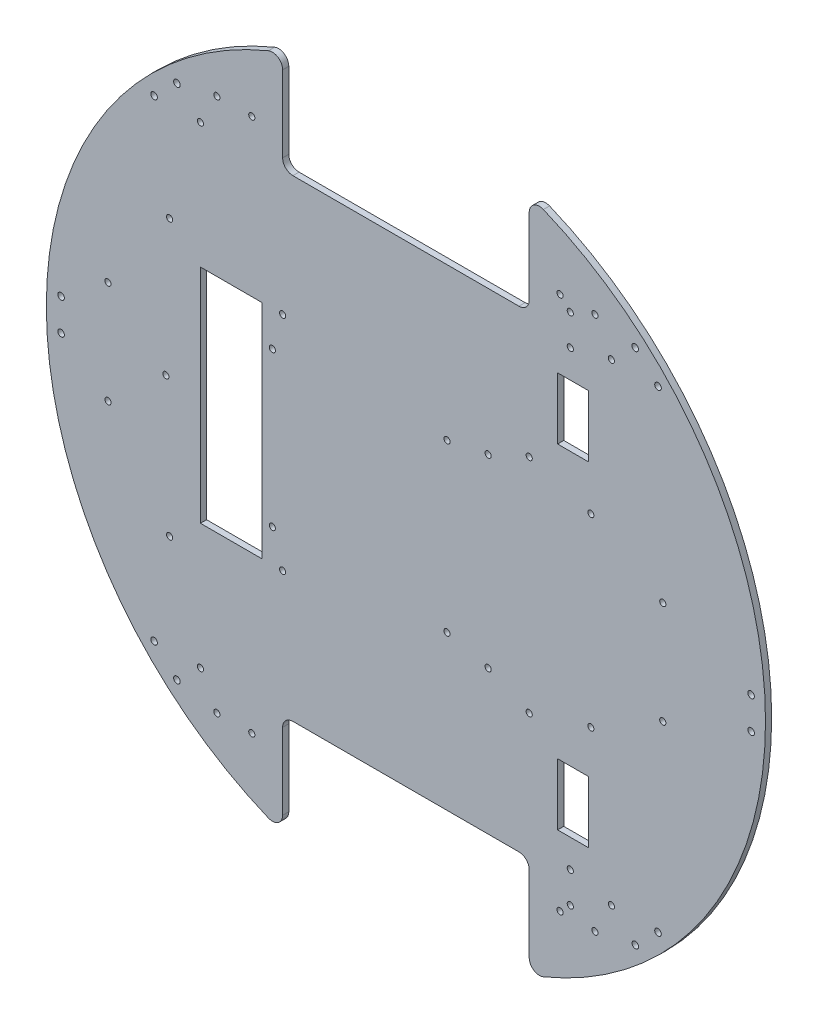
from build123d import *

# Parameters (mm, degrees)
SKETCH_1_R             = 175
EXTRUDE_1_DEPTH        = 3
CUT_EXTRUDE_1_DEPTH    = 3
FILLET_1_R             = 5
FILLET_2_R             = 5
FILLET_3_R             = 5
SKETCH_5_R             = 1.5
CUT_EXTRUDE_4_DEPTH    = 3
SKETCH_6_R             = 1.5
CUT_EXTRUDE_5_DEPTH    = 3
SKETCH_7_W             = 30
SKETCH_7_H             = 108
CUT_EXTRUDE_6_DEPTH    = 3
SKETCH_8_R             = 1.5
CUT_EXTRUDE_7_DEPTH    = 3
SKETCH_9_R             = 1.5
CUT_EXTRUDE_8_DEPTH    = 10
SKETCH_10_R            = 1.6
CUT_EXTRUDE_5158_DEPTH = 10
SKETCH_11_W            = 15
SKETCH_11_H            = 30
CUT_EXTRUDE_10_DEPTH   = 10
SKETCH_19_R            = 1.6
CUT_EXTRUDE_8157_DEPTH = 10
SKETCH_21_R            = 1.5
WEB_DEPTH              = 10
SKETCH_22_R            = 1.5
WEB_2_DEPTH            = 10
SKETCH_28_R            = 1.5
CUT_EXTRUDE_9035_DEPTH = 10
SKETCH_29_R            = 1.5
CUT_EXTRUDE_9316_DEPTH = 10
SKETCH_31_R            = 1.5
CUT_EXTRUDE_9726_DEPTH = 10


with BuildPart() as part:
    # ｽｹｯﾁ1 → ﾎﾞｽ - 押し出し1 (new body)
    with BuildSketch(Plane.XY):
        Circle(SKETCH_1_R)
    extrude(amount=EXTRUDE_1_DEPTH)

    # ｽｹｯﾁ2 → ｶｯﾄ - 押し出し1 (cut)
    with BuildSketch(Plane.XY.offset(3)):
        with BuildLine():
            Line((-60, 115), (0, 115))
            Line((0, 115), (0, 175))
            ThreePointArc((0, 175), (-30.465194158, 172.327803749), (-60, 164.392822228))
            Line((-60, 164.392822228), (-60, 115))
        make_face()
        with BuildLine():
            Line((0, 175), (0, 115))
            Line((0, 115), (60, 115))
            Line((60, 115), (60, 164.392822228))
            ThreePointArc((60, 164.392822228), (30.465194158, 172.327803749), (0, 175))
        make_face()
        with BuildLine():
            Line((0, -175), (0, -115))
            Line((0, -115), (-60, -115))
            Line((-60, -115), (-60, -164.392822228))
            ThreePointArc((-60, -164.392822228), (-30.465194158, -172.327803749), (0, -175))
        make_face()
        with BuildLine():
            Line((60, -115), (0, -115))
            Line((0, -115), (0, -175))
            ThreePointArc((0, -175), (30.465194158, -172.327803749), (60, -164.392822228))
            Line((60, -164.392822228), (60, -115))
        make_face()
    extrude(amount=-CUT_EXTRUDE_1_DEPTH, mode=Mode.SUBTRACT)

    # ﾌｨﾚｯﾄ1
    fillet_1_edges = [part.edges().sort_by_distance(p)[0] for p in [
        (-60, 164.392822228, 1.5),
    ]]
    fillet(fillet_1_edges, radius=FILLET_1_R)

    # ﾌｨﾚｯﾄ2
    fillet_2_edges = [part.edges().sort_by_distance(p)[0] for p in [
        (-60, 115, 1.5),
        (60, 164.392822228, 1.5),
        (60, 115, 1.5),
    ]]
    fillet(fillet_2_edges, radius=FILLET_2_R)

    # ﾌｨﾚｯﾄ3
    fillet_3_edges = [part.edges().sort_by_distance(p)[0] for p in [
        (-60, -115, 1.5),
        (60, -115, 1.5),
        (60, -164.392822228, 1.5),
        (-60, -164.392822228, 1.5),
    ]]
    fillet(fillet_3_edges, radius=FILLET_3_R)

    # ｽｹｯﾁ5 → ｶｯﾄ - 押し出し4 (cut)
    with BuildSketch(Plane.XY.offset(3)):
        with Locations((-100, -115)):
            Circle(SKETCH_5_R)
        with Locations((100, -115)):
            Circle(SKETCH_5_R)
        with Locations((100, 115)):
            Circle(SKETCH_5_R)
        with Locations((-100, 115)):
            Circle(SKETCH_5_R)
    extrude(amount=-CUT_EXTRUDE_4_DEPTH, mode=Mode.SUBTRACT)

    # ｽｹｯﾁ6 → ｶｯﾄ - 押し出し5 (cut)
    with BuildSketch(Plane.XY.offset(3)):
        with Locations((-60, 54)):
            Circle(SKETCH_6_R)
        with Locations((60, 54)):
            Circle(SKETCH_6_R)
        with Locations((-60, -54)):
            Circle(SKETCH_6_R)
        with Locations((60, -54)):
            Circle(SKETCH_6_R)
    extrude(amount=-CUT_EXTRUDE_5_DEPTH, mode=Mode.SUBTRACT)

    # ｽｹｯﾁ7 → ｶｯﾄ - 押し出し6 (cut)
    with BuildSketch(Plane.XY.offset(3)):
        with Locations((-85, 0)):
            Rectangle(SKETCH_7_W, SKETCH_7_H)
    extrude(amount=-CUT_EXTRUDE_6_DEPTH, mode=Mode.SUBTRACT)

    # ｽｹｯﾁ8 → ｶｯﾄ - 押し出し7 (cut)
    with BuildSketch(Plane.XY.offset(3)):
        with Locations((-115, -67)):
            Circle(SKETCH_8_R)
        with Locations((-116.822468618, 0)):
            Circle(SKETCH_8_R)
        with Locations((-115, 67)):
            Circle(SKETCH_8_R)
    extrude(amount=-CUT_EXTRUDE_7_DEPTH, mode=Mode.SUBTRACT)

    # ｽｹｯﾁ9 → ｶｯﾄ - 押し出し8 (cut)
    with BuildSketch(Plane.XY.offset(3)):
        with Locations((-65, 37)):
            Circle(SKETCH_9_R)
        with Locations((20, 41)):
            Circle(SKETCH_9_R)
        with Locations((-65, -38)):
            Circle(SKETCH_9_R)
        with Locations((20, -40)):
            Circle(SKETCH_9_R)
    extrude(amount=-CUT_EXTRUDE_8_DEPTH, mode=Mode.SUBTRACT)

    # ｽｹｯﾁ10 → Cut-Extrude 5158 (cut)
    with BuildSketch(Plane.XY.offset(3)):
        with Locations((111.643659725, -125.921059639)):
            Circle(SKETCH_10_R)
        with Locations((122.679794489, -115.037952538)):
            Circle(SKETCH_10_R)
        with Locations((168, 7.75)):
            Circle(SKETCH_10_R)
        with Locations((168, -7.75)):
            Circle(SKETCH_10_R)
        with Locations((111.56768007, 125.844011632)):
            Circle(SKETCH_10_R)
        with Locations((122.679794489, 115.037952538)):
            Circle(SKETCH_10_R)
    extrude(amount=-CUT_EXTRUDE_5158_DEPTH, mode=Mode.SUBTRACT)

    # ｽｹｯﾁ11 → ｶｯﾄ - 押し出し10 (cut)
    with BuildSketch(Plane.XY.offset(3)):
        with Locations((81.317279836, 81.317279836)):
            Rectangle(SKETCH_11_W, SKETCH_11_H)
        with Locations((81.317279836, -81.317279836)):
            Rectangle(SKETCH_11_W, SKETCH_11_H)
    extrude(amount=-CUT_EXTRUDE_10_DEPTH, mode=Mode.SUBTRACT)

    # ｽｹｯﾁ19 → Cut-Extrude 8157 (cut)
    with BuildSketch(Plane.XY.offset(3)):
        with Locations((-111.442990249, 125.715790275)):
            Circle(SKETCH_19_R)
        with Locations((-122.555104667, 114.909731181)):
            Circle(SKETCH_19_R)
        with Locations((-167.821147356, 7.75)):
            Circle(SKETCH_19_R)
        with Locations((-167.821147356, -7.75)):
            Circle(SKETCH_19_R)
        with Locations((-122.555104667, -114.909731181)):
            Circle(SKETCH_19_R)
        with Locations((-111.442990249, -125.715790275)):
            Circle(SKETCH_19_R)
    extrude(amount=-CUT_EXTRUDE_8157_DEPTH, mode=Mode.SUBTRACT)

    # ｽｹｯﾁ21 → Web (cut)
    with BuildSketch(Plane.XY.offset(3)):
        with Locations((-145, 25)):
            Circle(SKETCH_21_R)
        with Locations((-145, -25)):
            Circle(SKETCH_21_R)
    extrude(amount=-WEB_DEPTH, mode=Mode.SUBTRACT)

    # ｽｹｯﾁ22 → Web 2 (cut)
    with BuildSketch(Plane.XY.offset(3)):
        with Locations((125, 25)):
            Circle(SKETCH_22_R)
        with Locations((125, -25)):
            Circle(SKETCH_22_R)
    extrude(amount=-WEB_2_DEPTH, mode=Mode.SUBTRACT)

    # ｽｹｯﾁ28 → Cut-Extrude 9035 (cut)
    with BuildSketch(Plane.XY.offset(3)):
        with Locations((40, 45)):
            Circle(SKETCH_28_R)
        with Locations((90, 45)):
            Circle(SKETCH_28_R)
        with Locations((40, -45)):
            Circle(SKETCH_28_R)
        with Locations((90, -45)):
            Circle(SKETCH_28_R)
    extrude(amount=-CUT_EXTRUDE_9035_DEPTH, mode=Mode.SUBTRACT)

    # ｽｹｯﾁ29 → Cut-Extrude 9316 (cut)
    with BuildSketch(Plane.XY.offset(3)):
        with Locations((80, 125)):
            Circle(SKETCH_29_R)
        with Locations((80, 110)):
            Circle(SKETCH_29_R)
        with Locations((80, -110)):
            Circle(SKETCH_29_R)
        with Locations((80, -125)):
            Circle(SKETCH_29_R)
    extrude(amount=-CUT_EXTRUDE_9316_DEPTH, mode=Mode.SUBTRACT)

    # ｽｹｯﾁ31 → Cut-Extrude 9726 (cut)
    with BuildSketch(Plane.XY.offset(3)):
        with Locations((-92, 130)):
            Circle(SKETCH_31_R)
        with Locations((-75, 130)):
            Circle(SKETCH_31_R)
        with Locations((75, 130)):
            Circle(SKETCH_31_R)
        with Locations((92, 130)):
            Circle(SKETCH_31_R)
        with Locations((92, -130)):
            Circle(SKETCH_31_R)
        with Locations((75, -130)):
            Circle(SKETCH_31_R)
        with Locations((-75, -130)):
            Circle(SKETCH_31_R)
        with Locations((-92, -130)):
            Circle(SKETCH_31_R)
    extrude(amount=-CUT_EXTRUDE_9726_DEPTH, mode=Mode.SUBTRACT)


solid = part.part
